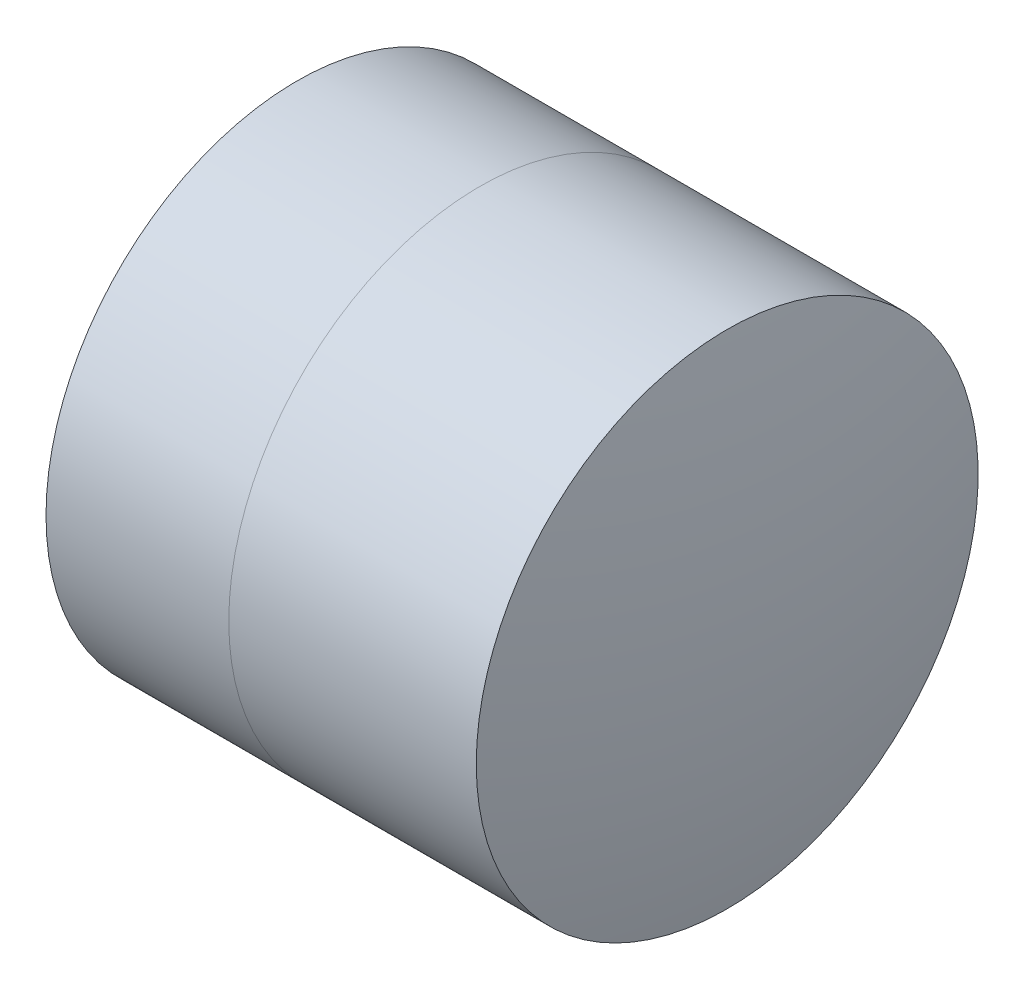
from build123d import *


with BuildPart() as part:
    # 草图1 one side → 旋转1 (revolve)
    with BuildSketch(Plane(origin=(0, 0, 0), x_dir=(1, 0, 0), z_dir=(0, 1, 0)), mode=Mode.PRIVATE) as revolve_1_sk:
        with BuildLine():
            ThreePointArc((2.247593992, 2.5), (2.058340793, 1.256362025), (1.995042706, 0))
            Line((1.995042706, 0), (4.695042706, 0))
            ThreePointArc((4.695042706, 0), (4.535988215, 1.288673453), (4.068371284, 2.5))
            Line((4.068371284, 2.5), (2.247593992, 2.5))
        make_face()
    revolve(revolve_1_sk.sketch.rotate(Axis((-0.816062176, 0, 0), (1, 0, 0)), 180), axis=Axis((-0.816062176, 0, 0), (1, 0, 0)))  # turned: the seam where the file's is


with BuildPart() as body_2:
    # 草图2 one side → 旋转3 (revolve)
    with BuildSketch(Plane(origin=(0, 0, 0), x_dir=(1, 0, 0), z_dir=(0, 1, 0)), mode=Mode.PRIVATE) as revolve_3_sk:
        with BuildLine():
            Line((6.533961575, 2.5), (4.068371284, 2.5))
            ThreePointArc((4.068371284, 2.5), (4.535988215, 1.288673453), (4.695042706, 0))
            Line((4.695042706, 0), (6.795042706, 0))
            ThreePointArc((6.795042706, 0), (6.729595425, 1.256797851), (6.533961575, 2.5))
        make_face()
    revolve(revolve_3_sk.sketch.rotate(Axis((-0.551919993, 0, 0), (1, 0, 0)), 180), axis=Axis((-0.551919993, 0, 0), (1, 0, 0)))  # turned: the seam where the file's is


solid = Compound([part.part, body_2.part])
